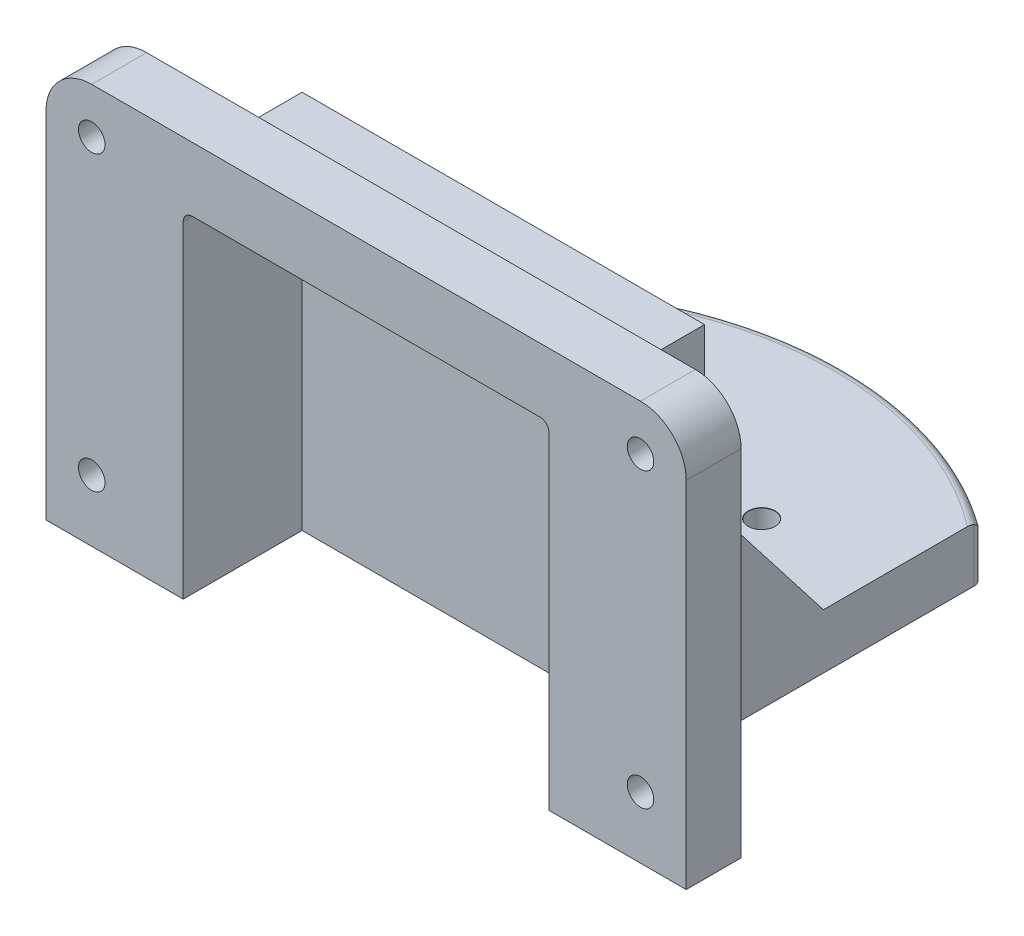
from build123d import *

# Parameters (mm, degrees)
SKETCH_1_W                     = 70
SKETCH_1_H                     = 43.75
EXTRUDE_1_DEPTH                = 6
EXTRUDE_2_DEPTH                = 15
CUT_EXTRUDE_1_DEPTH            = 13
EXTRUDE_4_DEPTH                = 6
EXTRUDE_5_DEPTH                = 44
FILLET_3_R                     = 1
FILLET_5_R                     = 4
FILLET_6_R                     = 1
FILLET_7_R                     = 5
HOLE_WIZARD_M2_5_1_D           = 2.9
HOLE_WIZARD_M2_5_1_CSINK_D     = 2.95
HOLE_WIZARD_M2_5_1_CSINK_ANGLE = 90
HOLE_WIZARD_M2_5_3_D           = 2.9
HOLE_WIZARD_M2_5_3_CSINK_D     = 2.95
HOLE_WIZARD_M2_5_3_CSINK_ANGLE = 90


with BuildPart() as part:
    # 草图1 → 凸台-拉伸1 (new body)
    with BuildSketch(Plane.XY):
        with Locations((-14, -16.875)):
            Rectangle(SKETCH_1_W, SKETCH_1_H)
    extrude(amount=EXTRUDE_1_DEPTH)

    # 草图2 → 凸台-拉伸2 (add)
    with BuildSketch(Plane.XY.offset(6)):
        Polygon((-13.907811237, 0.75), (8, 0.75), (8, -38.75), (-36, -38.75), (-36, 0.75), align=None)
    extrude(amount=-EXTRUDE_2_DEPTH)

    # 草图3 → 切除-拉伸1 (cut)
    with BuildSketch(Plane.XY.offset(6)):
        Polygon((-14, -2), (6, -2), (6, -38.75), (-34, -38.75), (-34, -2), align=None)
    extrude(amount=-CUT_EXTRUDE_1_DEPTH, mode=Mode.SUBTRACT)

    # 草图5 → 凸台-拉伸4 (add)
    with BuildSketch(Plane.XZ.offset(38.75)):
        with BuildLine():
            Line((-36, -9), (-36, -39))
            ThreePointArc((-36, -39), (-14, -46.202150475), (8, -39))
            Line((8, -39), (8, -9))
            Line((8, -9), (-36, -9))
        make_face()
    extrude(amount=-EXTRUDE_4_DEPTH)

    # 草图12 → 凸台-拉伸5 (add)
    with BuildSketch(Plane(origin=(8, 0, 0), x_dir=(0, 0, -1), z_dir=(1, 0, 0))):
        Polygon((9, -32.75), (22, -32.75), (9, -16), align=None)
    extrude(amount=-EXTRUDE_5_DEPTH)

    # 圆角3
    fillet_3_edges = [part.edges().sort_by_distance(p)[0] for p in [
        (-36, -35.75, -39),
        (-14, -32.75, -46.202150475),
        (8, -35.75, -39),
    ]]
    fillet(fillet_3_edges, radius=FILLET_3_R)

    # 圆角5
    fillet_5_edges = [part.edges().sort_by_distance(p)[0] for p in [
        (8, -19, 0),
        (-36, -19, 0),
    ]]
    fillet(fillet_5_edges, radius=FILLET_5_R)

    # 圆角6
    fillet_6_edges = [part.edges().sort_by_distance(p)[0] for p in [
        (6, -2, -0.5),
        (-34, -2, -0.5),
    ]]
    fillet(fillet_6_edges, radius=FILLET_6_R)

    # 圆角7
    fillet_7_edges = [part.edges().sort_by_distance(p)[0] for p in [
        (-49, 5, 3),
        (21, 5, 3),
    ]]
    fillet(fillet_7_edges, radius=FILLET_7_R)

    # M2.5 间隙孔1 (through all)
    with Locations(Plane(origin=(0, 0, 0), x_dir=(-1, 0, 0), z_dir=(0, 0, -1))):
        with Locations((-16, 0), (-16, -32), (44, -32), (44, 0)):
            CounterSinkHole(HOLE_WIZARD_M2_5_1_D / 2, HOLE_WIZARD_M2_5_1_CSINK_D / 2, counter_sink_angle=HOLE_WIZARD_M2_5_1_CSINK_ANGLE)

    # M2.5 间隙孔3 (through all)
    with Locations(Plane(origin=(0, -32.75, 0), x_dir=(1, 0, 0), z_dir=(0, 1, 0))):
        with Locations((-24, 27.25), (-4, 27.25)):
            CounterSinkHole(HOLE_WIZARD_M2_5_3_D / 2, HOLE_WIZARD_M2_5_3_CSINK_D / 2, counter_sink_angle=HOLE_WIZARD_M2_5_3_CSINK_ANGLE)


solid = part.part
